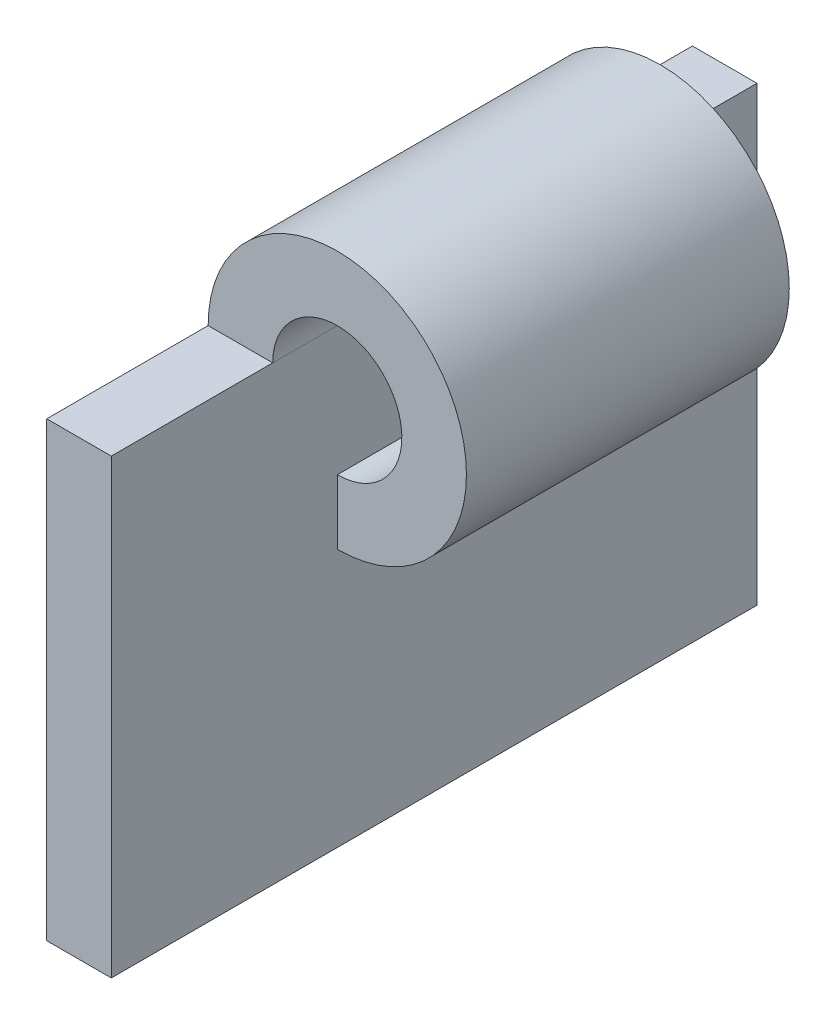
from build123d import *

# Parameters (mm, degrees)
BOSS_EXTRUDE1_DEPTH = 20
BOSS_EXTRUDE2_START = 5
BOSS_EXTRUDE2_DEPTH = 10


with BuildPart() as part:
    # Sketch2 → Boss-Extrude1 (new body)
    with BuildSketch(Plane.XY):
        Polygon((0, 14), (0, 0), (2, 0), (2, 10.535898385), (2, 14), align=None)
    extrude(amount=BOSS_EXTRUDE1_DEPTH)


with BuildPart() as body_2:
    # Sketch2_8 → Boss-Extrude2 (new body)
    with BuildSketch(Plane.XY.offset(BOSS_EXTRUDE2_START)):
        with BuildLine():
            ThreePointArc((4, 10), (6.828427125, 16.828427125), (0, 14))
            Line((0, 14), (2, 14))
            ThreePointArc((2, 14), (4, 16), (6, 14))
            ThreePointArc((6, 14), (5.414213562, 12.585786438), (4, 12))
            Line((4, 12), (4, 10))
        make_face()
    extrude(amount=BOSS_EXTRUDE2_DEPTH)


solid = Compound([part.part, body_2.part])
